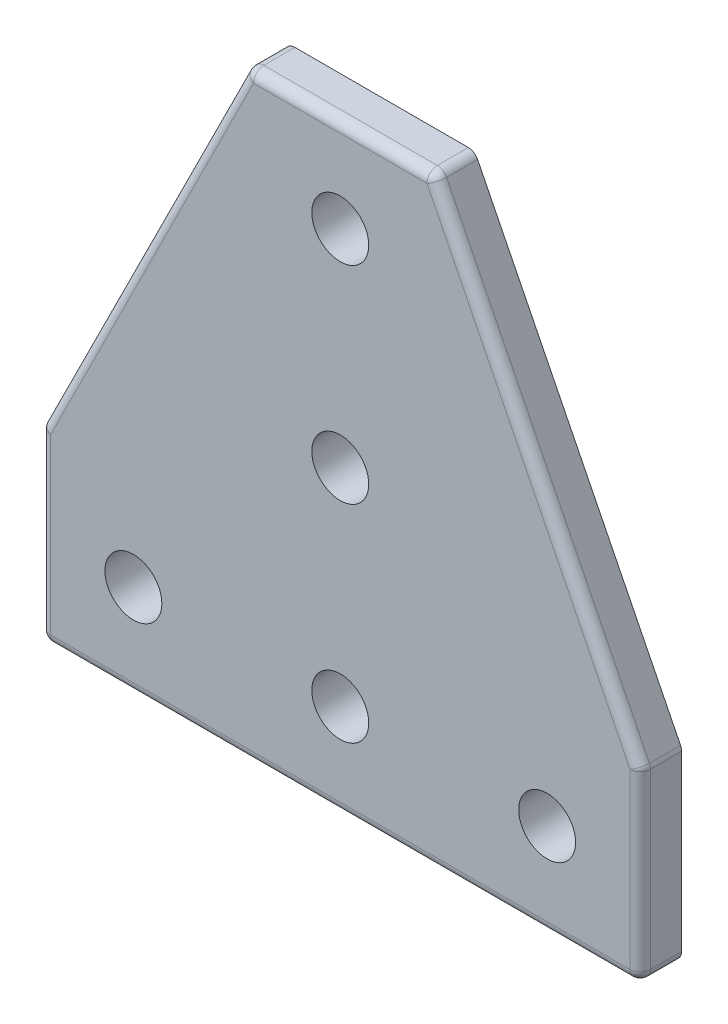
from build123d import *

# Parameters (mm, degrees)
SKETCH1_R           = 2.75
BOSS_EXTRUDE1_DEPTH = 2
FILLET1_R           = 1


with BuildPart() as part:
    # Sketch1 → Boss-Extrude1 (new body, symmetric)
    with BuildSketch(Plane.XY):
        Polygon((0, 0), (0, 18), (20, 58), (38, 58), (58, 18), (58, 0), align=None)
        with Locations((9, 9)):
            Circle(SKETCH1_R, mode=Mode.SUBTRACT)
        with Locations((29, 9)):
            Circle(SKETCH1_R, mode=Mode.SUBTRACT)
        with Locations((49, 9)):
            Circle(SKETCH1_R, mode=Mode.SUBTRACT)
        with Locations((29, 29)):
            Circle(SKETCH1_R, mode=Mode.SUBTRACT)
        with Locations((29, 49)):
            Circle(SKETCH1_R, mode=Mode.SUBTRACT)
    extrude(amount=BOSS_EXTRUDE1_DEPTH, both=True)

    # Fillet1
    fillet1_edges = [part.edges().sort_by_distance(p)[0] for p in [
        (48, 38, 2),
        (0, 0, 0),
        (0, 18, 0),
        (20, 58, 0),
        (38, 58, 0),
        (58, 18, 0),
        (58, 0, 0),
        (29, 58, 2),
        (10, 38, 2),
        (0, 9, 2),
        (29, 0, 2),
        (58, 9, 2),
    ]]
    fillet(fillet1_edges, radius=FILLET1_R)


solid = part.part
